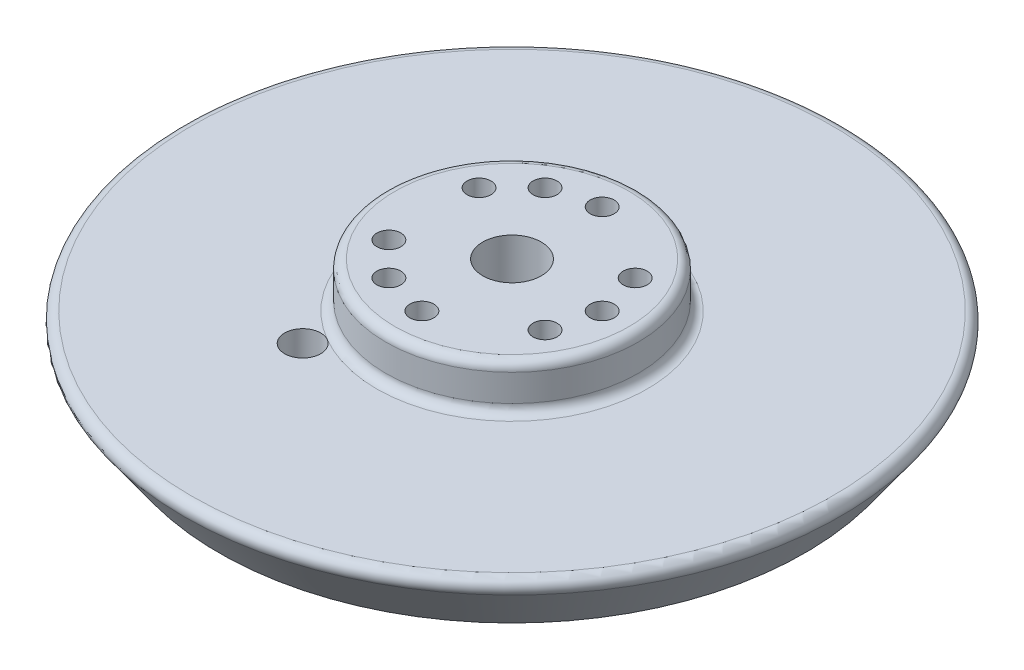
from build123d import *

# Parameters (mm, degrees)
CONG_1_R                = 1
ENL_V_MAT_EXTRU_1_REACH = 14
ESQUISSE2_R             = 3.25
ESQUISSE2_R_2           = 1.33
ESQUISSE2_R_3           = 2
CHANFREIN1_SIZE         = 2
ESQUISSE3_R             = 1.33
ENL_V_MAT_EXTRU_2_DEPTH = 5


with BuildPart() as part:
    # Esquisse1 → Révolution1 (revolve)
    with BuildSketch(Plane.XY):
        Polygon((14, -5), (37.5, -5), (32.5, -12), (0, -12), (0, 0), (14, 0), align=None)
    revolve(axis=Axis((0, 0, 0), (0, 1, 0)))

    # Congé1
    cong_1_edges = [part.edges().sort_by_distance(p)[0] for p in [
        (-37.5, -5, 0),
        (-14, -5, 0),
        (-14, 0, 0),
    ]]
    fillet(cong_1_edges, radius=CONG_1_R)

    # Esquisse2 → Enlèv. mat.-Extru.1 (cut, up to next)
    with BuildSketch(Plane.XZ.offset(12), mode=Mode.PRIVATE) as enl_v_mat_extru_1_sk1:
        Circle(ESQUISSE2_R)
    enl_v_mat_extru_1_tool1 = extrude(enl_v_mat_extru_1_sk1.sketch, amount=-ENL_V_MAT_EXTRU_1_REACH, mode=Mode.PRIVATE) & part.part
    add(enl_v_mat_extru_1_tool1.solids().sort_by_distance((0, -12, 0))[0], mode=Mode.SUBTRACT)
    # Esquisse2 → Enlèv. mat.-Extru.1 (cut, up to next)
    with BuildSketch(Plane.XZ.offset(12), mode=Mode.PRIVATE) as enl_v_mat_extru_1_sk2:
        with Locations((10, 0)):
            Circle(ESQUISSE2_R_2)
    enl_v_mat_extru_1_tool2 = extrude(enl_v_mat_extru_1_sk2.sketch, amount=-ENL_V_MAT_EXTRU_1_REACH, mode=Mode.PRIVATE) & part.part
    add(enl_v_mat_extru_1_tool2.solids().sort_by_distance((10, -12, 0))[0], mode=Mode.SUBTRACT)
    # Esquisse2 → Enlèv. mat.-Extru.1 (cut, up to next)
    with BuildSketch(Plane.XZ.offset(12), mode=Mode.PRIVATE) as enl_v_mat_extru_1_sk3:
        with Locations((-5, -8.660254038)):
            Circle(ESQUISSE2_R_2)
    enl_v_mat_extru_1_tool3 = extrude(enl_v_mat_extru_1_sk3.sketch, amount=-ENL_V_MAT_EXTRU_1_REACH, mode=Mode.PRIVATE) & part.part
    add(enl_v_mat_extru_1_tool3.solids().sort_by_distance((-5, -12, -8.660254))[0], mode=Mode.SUBTRACT)
    # Esquisse2 → Enlèv. mat.-Extru.1 (cut, up to next)
    with BuildSketch(Plane.XZ.offset(12), mode=Mode.PRIVATE) as enl_v_mat_extru_1_sk4:
        with Locations((-5, 8.660254038)):
            Circle(ESQUISSE2_R_2)
    enl_v_mat_extru_1_tool4 = extrude(enl_v_mat_extru_1_sk4.sketch, amount=-ENL_V_MAT_EXTRU_1_REACH, mode=Mode.PRIVATE) & part.part
    add(enl_v_mat_extru_1_tool4.solids().sort_by_distance((-5, -12, 8.660254))[0], mode=Mode.SUBTRACT)
    # Esquisse2 → Enlèv. mat.-Extru.1 (cut, up to next)
    with BuildSketch(Plane.XZ.offset(12), mode=Mode.PRIVATE) as enl_v_mat_extru_1_sk5:
        with Locations((-8.5, 14.722431864)):
            Circle(ESQUISSE2_R_3)
    enl_v_mat_extru_1_tool5 = extrude(enl_v_mat_extru_1_sk5.sketch, amount=-ENL_V_MAT_EXTRU_1_REACH, mode=Mode.PRIVATE) & part.part
    add(enl_v_mat_extru_1_tool5.solids().sort_by_distance((-8.5, -12, 14.722432))[0], mode=Mode.SUBTRACT)

    # Chanfrein1
    chanfrein1_edges = [part.edges().sort_by_distance(p)[0] for p in [
        (-3.25, -12, 0),
    ]]
    chamfer(chanfrein1_edges, length=CHANFREIN1_SIZE)

    # Esquisse3 → Enlèv. mat.-Extru.2 (cut)
    with BuildSketch(Plane(origin=(0, 0, 0), x_dir=(1, 0, 0), z_dir=(0, 1, 0))):
        with Locations((8.660254038, 5)):
            Circle(ESQUISSE3_R)
        with Locations((8.660254038, -5)):
            Circle(ESQUISSE3_R)
        with Locations((-8.660254038, -5)):
            Circle(ESQUISSE3_R)
        with Locations((0, -10)):
            Circle(ESQUISSE3_R)
        with Locations((0, 10)):
            Circle(ESQUISSE3_R)
        with Locations((-8.660254038, 5)):
            Circle(ESQUISSE3_R)
    extrude(amount=-ENL_V_MAT_EXTRU_2_DEPTH, mode=Mode.SUBTRACT)


solid = part.part
